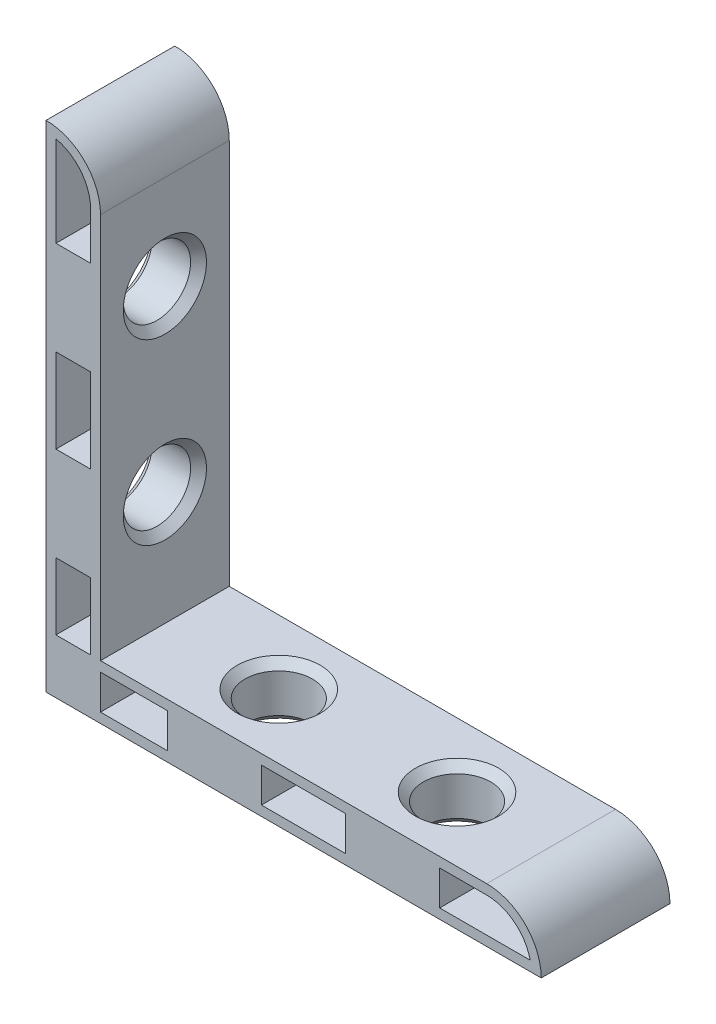
from build123d import *

# Parameters (mm, degrees)
EXTRUDE_1_DEPTH            = 6.5
EXTRUDE_START              = -6.5
SKETCH_2_W                 = 5.5
SKETCH_2_H                 = 5.5
SKETCH_2_H_2               = 9.5
SKETCH_2_W_2               = 9.5
EXTRUDE_2_DEPTH            = 13
EXTRUDE_3_DEPTH            = 1
HOLE_WIZARD_M81_AT_2_COUNT = 2
HOLE_WIZARD_M81_AT_2_PITCH = 18


with BuildPart() as part:
    # Эскиз1 → Бобышка-Вытянуть1 (new body, symmetric)
    with BuildSketch(Plane.XY):
        with BuildLine():
            Line((0, 50), (0, 0))
            Line((0, 0), (50, 0))
            ThreePointArc((50, 0), (48.389087297, 3.889087297), (44.5, 5.5))
            Line((44.5, 5.5), (5.5, 5.5))
            Line((5.5, 5.5), (5.5, 44.5))
            ThreePointArc((5.5, 44.5), (3.889087297, 48.389087297), (0, 50))
        make_face()
        with BuildLine():
            Line((1, 48.887482194), (1, 1))
            Line((1, 1), (48.887482194, 1))
            ThreePointArc((48.887482194, 1), (47.30624304, 3.51781182), (44.5, 4.5))
            Line((44.5, 4.5), (4.5, 4.5))
            Line((4.5, 4.5), (4.5, 44.5))
            ThreePointArc((4.5, 44.5), (3.51781182, 47.30624304), (1, 48.887482194))
        make_face(mode=Mode.SUBTRACT)
    extrude(amount=EXTRUDE_1_DEPTH, both=True)

    # Эскиз2 → Бобышка-Вытянуть2 (add)
    with BuildSketch(Plane.XY.offset(EXTRUDE_START)):
        with Locations((2.75, 2.75)):
            Rectangle(SKETCH_2_W, SKETCH_2_H)
        with Locations((2.75, 35)):
            Rectangle(SKETCH_2_W, SKETCH_2_H_2)
        with Locations((2.75, 17)):
            Rectangle(SKETCH_2_W, SKETCH_2_H_2)
        with Locations((17, 2.75)):
            Rectangle(SKETCH_2_W_2, SKETCH_2_H)
        with Locations((35, 2.75)):
            Rectangle(SKETCH_2_W_2, SKETCH_2_H)
    extrude(amount=EXTRUDE_2_DEPTH)

    # Эскиз3 → Бобышка-Вытянуть3 (add, symmetric)
    with BuildSketch(Plane.XY):
        with BuildLine():
            Line((0, 0), (50, 0))
            ThreePointArc((50, 0), (48.389087297, 3.889087297), (44.5, 5.5))
            Line((44.5, 5.5), (5.5, 5.5))
            Line((5.5, 5.5), (5.5, 44.5))
            ThreePointArc((5.5, 44.5), (3.889087297, 48.389087297), (0, 50))
            Line((0, 50), (0, 0))
        make_face()
    extrude(amount=EXTRUDE_3_DEPTH, both=True)

    # Эскиз5 → Отверстие обработанное метчиком M81 (revolve, cut)
    with BuildSketch(Plane.ZX.offset(35)):
        Polygon((0, 0), (0, 5.5), (4.2, 5.5), (3.4, 4.7), (3.4, 0.8), (4.2, 0), align=None)
    hole_wizard_m81 = revolve(axis=Axis((-6.35, 35, 0), (1, 0, 0)), mode=Mode.SUBTRACT)

    # Отверстие обработанное метчиком M81 at 2: Отверстие обработанное метчиком M81 ×2
    with Locations(*[(0, -i * HOLE_WIZARD_M81_AT_2_PITCH, 0) for i in range(1, HOLE_WIZARD_M81_AT_2_COUNT)]):
        add(hole_wizard_m81, mode=Mode.SUBTRACT)

    # Зеркальное отражение1: Отверстие обработанное метчиком M81 across plane
    add(hole_wizard_m81.mirror(Plane(origin=(0, 0, 0), x_dir=(0, 0, 1), z_dir=(-0.707106781, 0.707106781, 0))), mode=Mode.SUBTRACT)

    # Зеркальное отражение1 copy 1 sketch → Зеркальное отражение1 copy 1 (revolve, cut)
    with BuildSketch(Plane(origin=(17, 0, 0), x_dir=(0, 0, 1), z_dir=(1, 0, 0))):
        Polygon((0, 0), (0, -5.5), (4.2, -5.5), (3.4, -4.7), (3.4, -0.8), (4.2, 0), align=None)
    revolve(axis=Axis((17, -6.35, 0), (0, -1, 0)), mode=Mode.SUBTRACT)


solid = part.part
